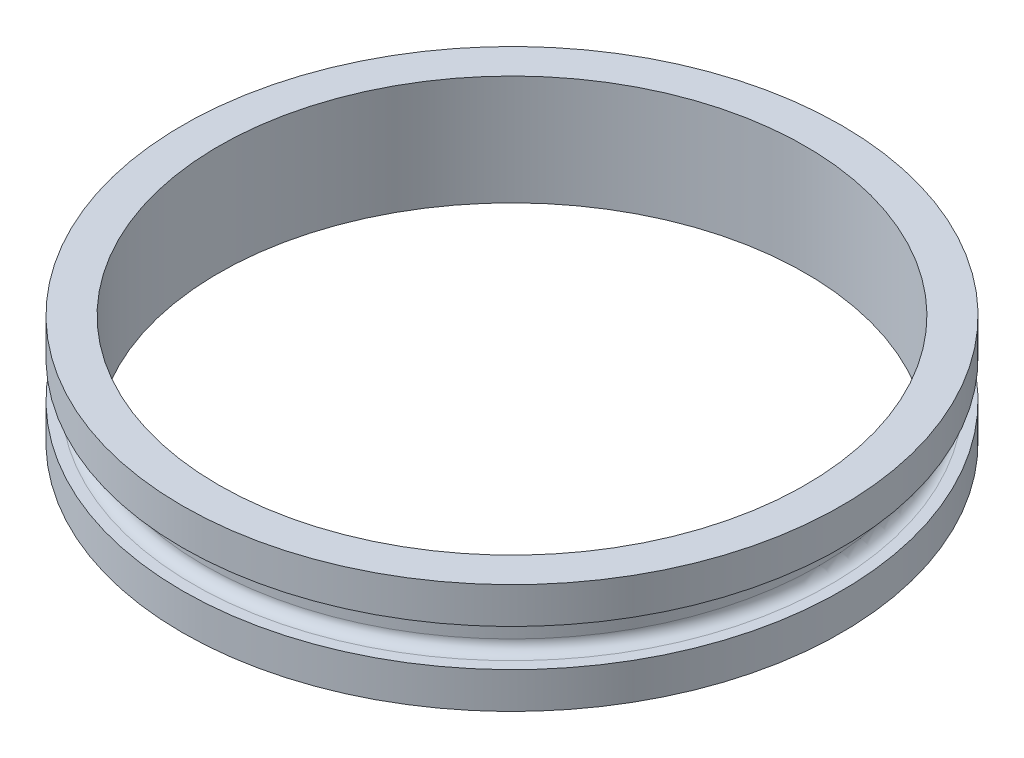
from build123d import *

# Parameters (mm, degrees)
FILLET1_R = 1.27


with BuildPart() as part:
    # Sketch1 → Revolve1 (revolve)
    with BuildSketch(Plane.XY):
        Polygon((33.9217, 0), (33.9217, 12.7), (38.1, 12.7), (38.1, 8.509), (35.56, 8.509), (35.56, 4.191), (38.1, 4.191), (38.1, 0), align=None)
    revolve(axis=Axis((0, 13.335, 0), (0, -1, 0)))

    # Fillet1
    fillet1_edges = [part.edges().sort_by_distance(p)[0] for p in [
        (-35.56, 4.191, 0),
        (-35.56, 8.509, 0),
    ]]
    fillet(fillet1_edges, radius=FILLET1_R)


solid = part.part
